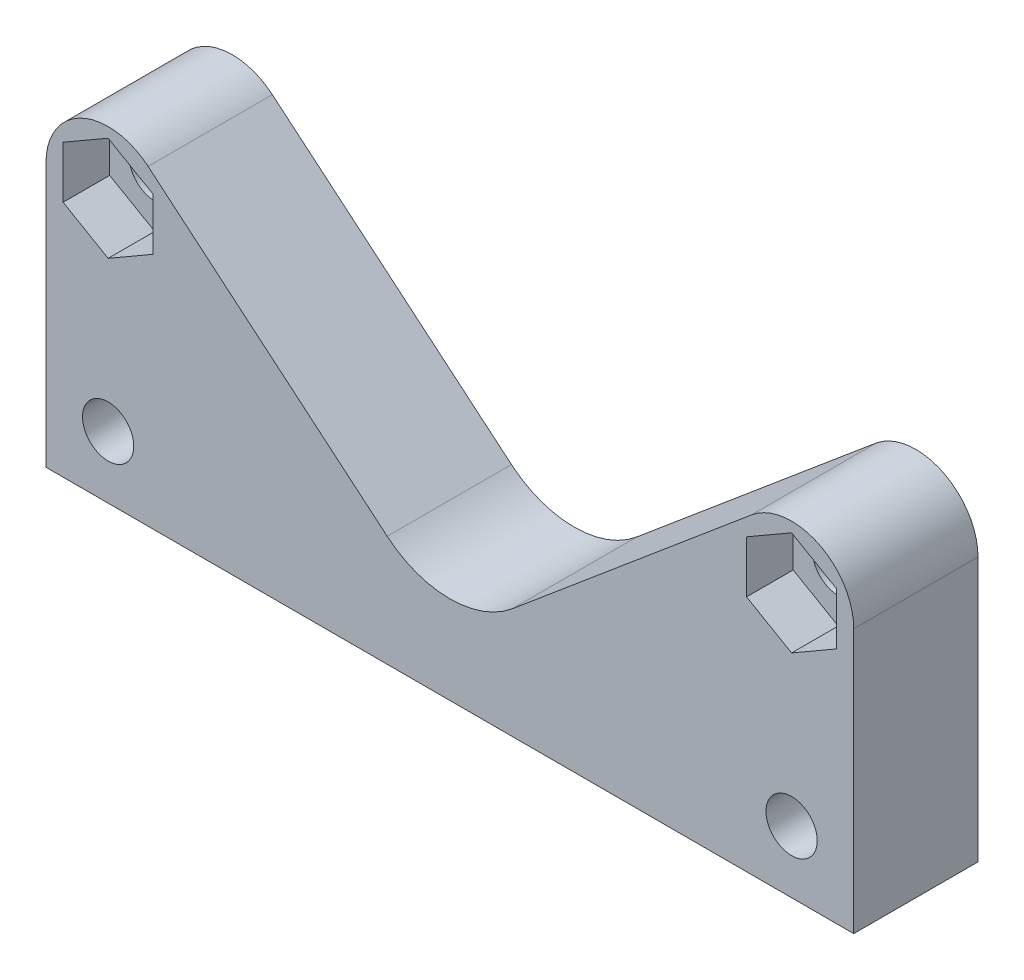
from build123d import *

# Parameters (mm, degrees)
SKETCH1_R           = 1.65
BOSS_EXTRUDE1_DEPTH = 8
CUT_EXTRUDE1_DEPTH  = 3


with BuildPart() as part:
    # Sketch1 → Boss-Extrude1 (new body)
    with BuildSketch(Plane.XY):
        with BuildLine():
            Line((0, 0), (52, 0))
            Line((52, 0), (52, 17))
            ThreePointArc((52, 17), (49.689734101, 20.625575633), (45.427600665, 20.06312939))
            Line((45.427600665, 20.06312939), (30.036241487, 7.137550003))
            ThreePointArc((30.036241487, 7.137550003), (26, 5.667546504), (21.963758513, 7.137550003))
            Line((21.963758513, 7.137550003), (6.572399335, 20.06312939))
            ThreePointArc((6.572399335, 20.06312939), (2.310265899, 20.625575633), (0, 17))
            Line((0, 17), (0, 0))
        make_face()
        with Locations((4, 17)):
            Circle(SKETCH1_R, mode=Mode.SUBTRACT)
        with Locations((48, 17)):
            Circle(SKETCH1_R, mode=Mode.SUBTRACT)
        with Locations((4, 4)):
            Circle(SKETCH1_R, mode=Mode.SUBTRACT)
        with Locations((48, 4)):
            Circle(SKETCH1_R, mode=Mode.SUBTRACT)
    extrude(amount=BOSS_EXTRUDE1_DEPTH)

    # Sketch2 → Cut-Extrude1 (cut)
    with BuildSketch(Plane.XY.offset(8)):
        Polygon((4, 13.651368439), (6.9, 15.325684219), (6.9, 18.674315781), (4, 20.348631561), (1.1, 18.674315781), (1.1, 15.325684219), align=None)
        Polygon((48, 13.651368439), (50.9, 15.325684219), (50.9, 18.674315781), (48, 20.348631561), (45.1, 18.674315781), (45.1, 15.325684219), align=None)
    extrude(amount=-CUT_EXTRUDE1_DEPTH, mode=Mode.SUBTRACT)


solid = part.part
